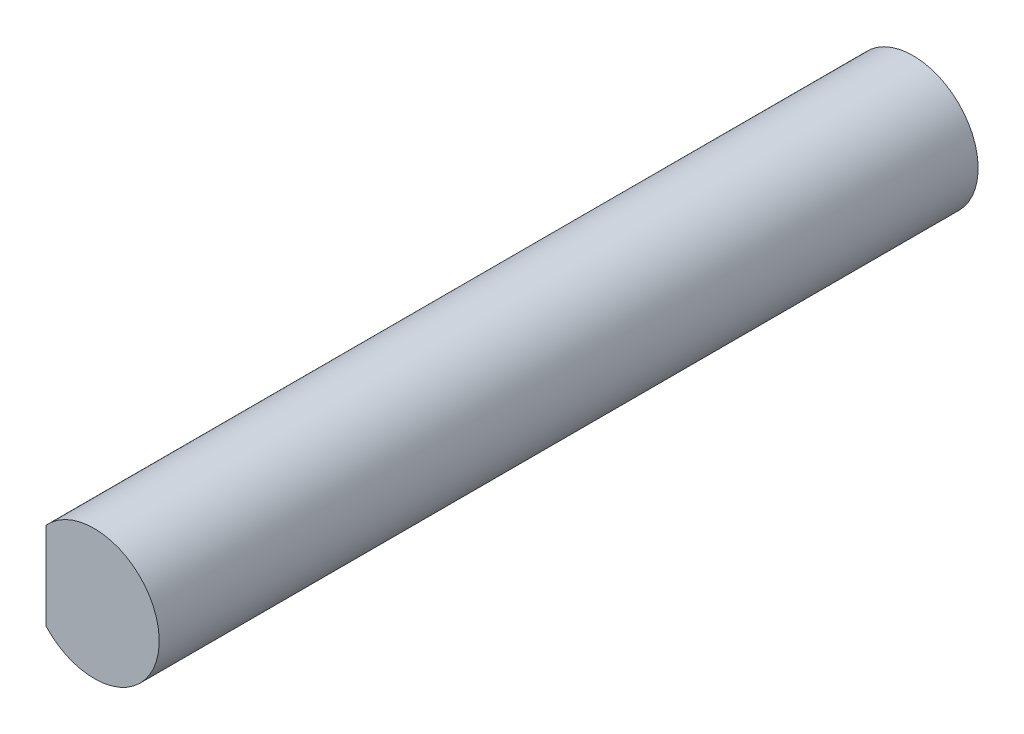
from build123d import *

# Parameters (mm, degrees)
SKETCH2_R           = 1.35
BOSS_EXTRUDE1_DEPTH = 8.5
CUT_EXTRUDE1_DEPTH  = 6.4
CUT_EXTRUDE2_DEPTH  = 3.2


with BuildPart() as part:
    # Sketch2 → Boss-Extrude1 (new body, symmetric)
    with BuildSketch(Plane.XY):
        Circle(SKETCH2_R)
    extrude(amount=BOSS_EXTRUDE1_DEPTH, both=True)

    # Sketch4 → Cut-Extrude1 (cut)
    with BuildSketch(Plane(origin=(0, 0, -8.5), x_dir=(-1, 0, 0), z_dir=(0, 0, -1))):
        with BuildLine():
            Line((1, 0.906917857), (1, -0.906917857))
            ThreePointArc((1, -0.906917857), (1.35, 0), (1, 0.906917857))
        make_face()
    extrude(amount=-CUT_EXTRUDE1_DEPTH, mode=Mode.SUBTRACT)

    # Sketch5 → Cut-Extrude2 (cut)
    with BuildSketch(Plane.XY.offset(8.5)):
        with BuildLine():
            Line((-1, 0.906917857), (-1, -0.906917857))
            ThreePointArc((-1, -0.906917857), (-1.35, 0), (-1, 0.906917857))
        make_face()
    extrude(amount=-CUT_EXTRUDE2_DEPTH, mode=Mode.SUBTRACT)


solid = part.part
